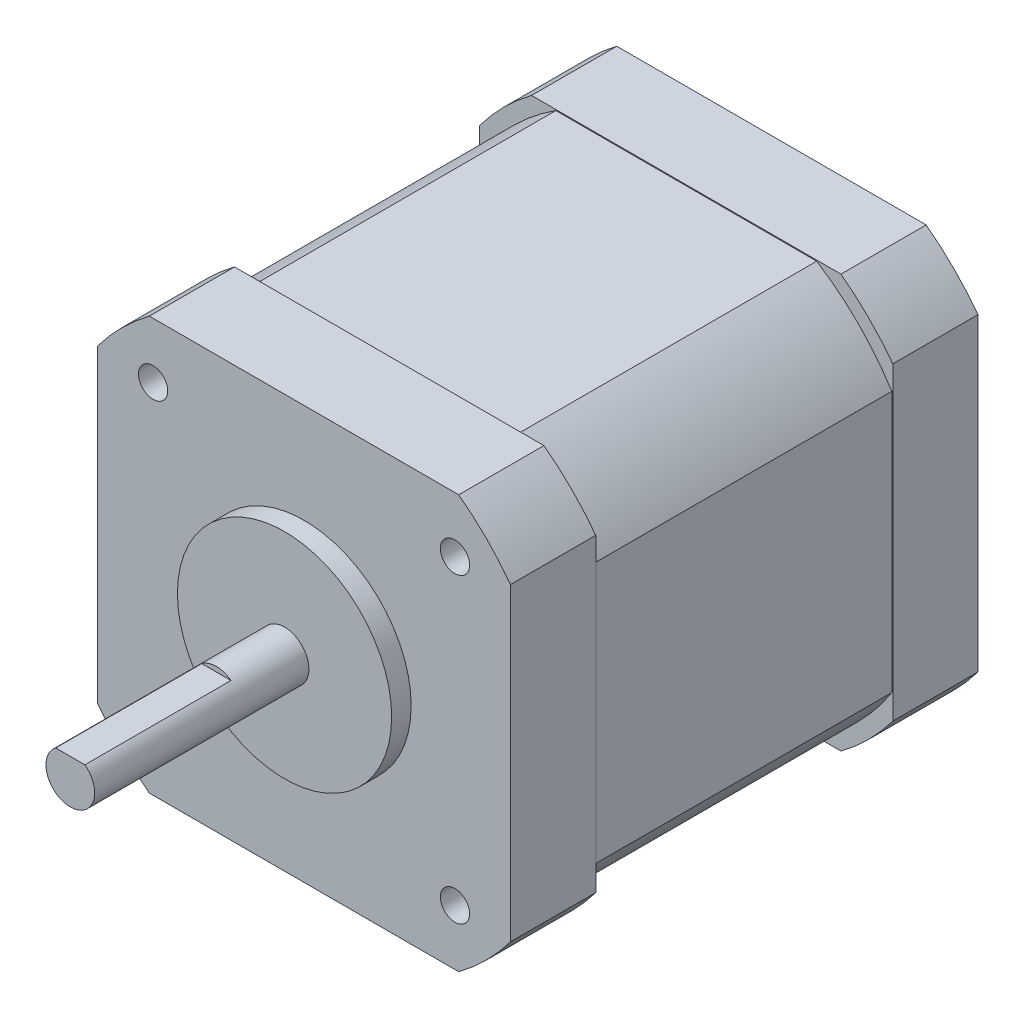
from build123d import *

# Parameters (mm, degrees)
BOSS_EXTRUDE1_DEPTH             = 8.75
BOSS_EXTRUDE2_DEPTH             = 30.5
BOSS_EXTRUDE3_DEPTH             = 8.75
SKETCH4_R                       = 11
BOSS_EXTRUDE4_DEPTH             = 2
SKETCH5_R                       = 2.5
BOSS_EXTRUDE5_DEPTH             = 22
CUT_EXTRUDE1_DEPTH              = 15
M3X0_5_TAPPED_HOLE1_D           = 2.5
M3X0_5_TAPPED_HOLE1_DEPTH       = 7.5
M3X0_5_TAPPED_HOLE1_CBORE_D     = 3
M3X0_5_TAPPED_HOLE1_CBORE_DEPTH = 6
M3X0_5_TAPPED_HOLE1_TIP         = 0.751075774


with BuildPart() as part:
    # Sketch1 → Boss-Extrude1 (new body)
    with BuildSketch(Plane.XY):
        with BuildLine():
            Line((-21.209, 15.887992919), (-21.209, -15.887992919))
            ThreePointArc((-21.209, -15.887992919), (-18.738329701, -18.738329701), (-15.887992919, -21.209))
            Line((-15.887992919, -21.209), (15.887992919, -21.209))
            ThreePointArc((15.887992919, -21.209), (18.738329701, -18.738329701), (21.209, -15.887992919))
            Line((21.209, -15.887992919), (21.209, 15.887992919))
            ThreePointArc((21.209, 15.887992919), (18.738329701, 18.738329701), (15.887992919, 21.209))
            Line((15.887992919, 21.209), (-15.887992919, 21.209))
            ThreePointArc((-15.887992919, 21.209), (-18.738329701, 18.738329701), (-21.209, 15.887992919))
        make_face()
    extrude(amount=-BOSS_EXTRUDE1_DEPTH)

    # Sketch2 → Boss-Extrude2 (add)
    with BuildSketch(Plane(origin=(0, 0, -8.75), x_dir=(-1, 0, 0), z_dir=(0, 0, -1))):
        with BuildLine():
            Line((-13.394406258, 21.109), (13.394406258, 21.109))
            ThreePointArc((13.394406258, 21.109), (17.67766953, 17.67766953), (21.109, 13.394406258))
            Line((21.109, 13.394406258), (21.109, -13.394406258))
            ThreePointArc((21.109, -13.394406258), (17.67766953, -17.67766953), (13.394406258, -21.109))
            Line((13.394406258, -21.109), (-13.394406258, -21.109))
            ThreePointArc((-13.394406258, -21.109), (-17.67766953, -17.67766953), (-21.109, -13.394406258))
            Line((-21.109, -13.394406258), (-21.109, 13.394406258))
            ThreePointArc((-21.109, 13.394406258), (-17.67766953, 17.67766953), (-13.394406258, 21.109))
        make_face()
    extrude(amount=BOSS_EXTRUDE2_DEPTH)

    # Sketch3 → Boss-Extrude3 (add)
    with BuildSketch(Plane.XY.offset(-39.25)):
        with BuildLine():
            Line((-15.887992919, -21.209), (15.887992919, -21.209))
            ThreePointArc((15.887992919, -21.209), (18.738329701, -18.738329701), (21.209, -15.887992919))
            Line((21.209, -15.887992919), (21.209, 15.887992919))
            ThreePointArc((21.209, 15.887992919), (18.738329701, 18.738329701), (15.887992919, 21.209))
            Line((15.887992919, 21.209), (-15.887992919, 21.209))
            ThreePointArc((-15.887992919, 21.209), (-18.738329701, 18.738329701), (-21.209, 15.887992919))
            Line((-21.209, 15.887992919), (-21.209, -15.887992919))
            ThreePointArc((-21.209, -15.887992919), (-18.738329701, -18.738329701), (-15.887992919, -21.209))
        make_face()
    extrude(amount=-BOSS_EXTRUDE3_DEPTH)

    # Sketch4 → Boss-Extrude4 (add)
    with BuildSketch(Plane.XY):
        Circle(SKETCH4_R)
    extrude(amount=BOSS_EXTRUDE4_DEPTH)

    # Sketch5 → Boss-Extrude5 (add)
    with BuildSketch(Plane.XY.offset(2)):
        Circle(SKETCH5_R)
    extrude(amount=BOSS_EXTRUDE5_DEPTH)

    # Sketch6 → Cut-Extrude1 (cut)
    with BuildSketch(Plane.XY.offset(24)):
        with BuildLine():
            Line((-1.5, 2), (1.5, 2))
            ThreePointArc((1.5, 2), (0, 2.5), (-1.5, 2))
        make_face()
    extrude(amount=-CUT_EXTRUDE1_DEPTH, mode=Mode.SUBTRACT)

    # M3x0.5 Tapped Hole1
    with Locations(Plane.XY):
        with Locations((-15.5, 15.5), (-15.5, -15.5), (15.5, -15.5), (15.5, 15.5)):
            CounterBoreHole(M3X0_5_TAPPED_HOLE1_D / 2, M3X0_5_TAPPED_HOLE1_CBORE_D / 2, M3X0_5_TAPPED_HOLE1_CBORE_DEPTH, depth=M3X0_5_TAPPED_HOLE1_DEPTH)
            with Locations((0, 0, -(M3X0_5_TAPPED_HOLE1_DEPTH + M3X0_5_TAPPED_HOLE1_TIP / 2))):  # 118° drill point
                Cone(0, M3X0_5_TAPPED_HOLE1_D / 2, M3X0_5_TAPPED_HOLE1_TIP, mode=Mode.SUBTRACT)


solid = part.part
